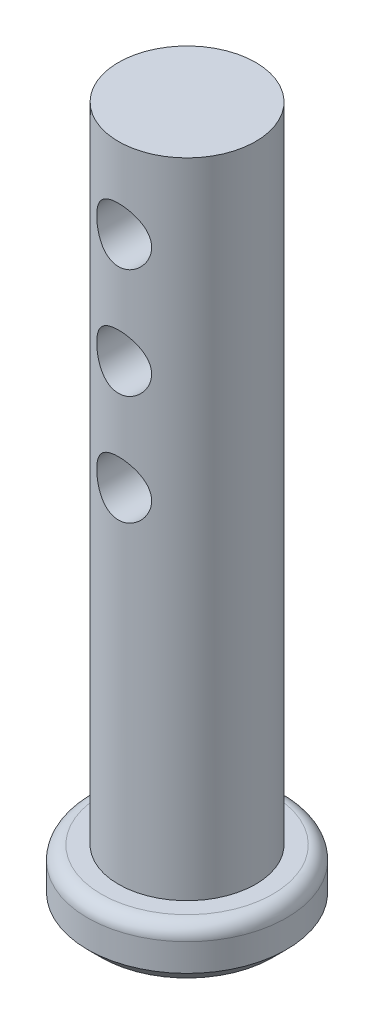
from build123d import *

# Parameters (mm, degrees)
SKETCH1_R               = 4.60375
BOSS_EXTRUDE1_DEPTH     = 2.54
SKETCH2_R               = 3.175
BOSS_EXTRUDE2_DEPTH     = 45.72
SKETCH3_R               = 1.27
CUT_EXTRUDE1_DEPTH      = 5.60375
CUT_EXTRUDE1_DEPTH_BACK = 5.60375
FILLET1_R               = 0.635
CHAMFER1_SIZE           = 0.635
SKETCH4_W               = 16.845680721
SKETCH4_H               = 19.604839444
CUT_EXTRUDE2_DEPTH      = 5.60375
CUT_EXTRUDE2_DEPTH_BACK = 5.6037501


with BuildPart() as part:
    # Sketch1 → Boss-Extrude1 (new body)
    with BuildSketch(Plane(origin=(0, 0, 0), x_dir=(1, 0, 0), z_dir=(0, 1, 0))):
        Circle(SKETCH1_R)
    extrude(amount=BOSS_EXTRUDE1_DEPTH)

    # Sketch2 → Boss-Extrude2 (add)
    with BuildSketch(Plane(origin=(0, 2.54, 0), x_dir=(1, 0, 0), z_dir=(0, 1, 0))):
        Circle(SKETCH2_R)
    extrude(amount=BOSS_EXTRUDE2_DEPTH)

    # Sketch3 → Cut-Extrude1 (cut, two sides)
    with BuildSketch(Plane.XY) as cut_extrude1_sk:
        with Locations((0, 18.415)):
            Circle(SKETCH3_R)
        with Locations((0, 23.495)):
            Circle(SKETCH3_R)
        with Locations((0, 28.575)):
            Circle(SKETCH3_R)
        with Locations((0, 33.655)):
            Circle(SKETCH3_R)
        with Locations((0, 38.735)):
            Circle(SKETCH3_R)
        with Locations((0, 43.815)):
            Circle(SKETCH3_R)
    extrude(amount=CUT_EXTRUDE1_DEPTH, mode=Mode.SUBTRACT)
    extrude(cut_extrude1_sk.sketch, amount=-CUT_EXTRUDE1_DEPTH_BACK, mode=Mode.SUBTRACT)

    # Fillet1
    fillet1_edges = [part.edges().sort_by_distance(p)[0] for p in [
        (-4.60375, 2.54, 0),
    ]]
    fillet(fillet1_edges, radius=FILLET1_R)

    # Chamfer1
    chamfer1_edges = [part.edges().sort_by_distance(p)[0] for p in [
        (-4.60375, 0, 0),
    ]]
    chamfer(chamfer1_edges, length=CHAMFER1_SIZE)

    # Sketch4 → Cut-Extrude2 (cut, two sides)
    with BuildSketch(Plane(origin=(0, 0, 0), x_dir=(0, 0, -1), z_dir=(1, 0, 0))) as cut_extrude2_sk:
        with Locations((1.010740844, 42.122953468)):
            Rectangle(SKETCH4_W, SKETCH4_H)
    extrude(amount=CUT_EXTRUDE2_DEPTH, mode=Mode.SUBTRACT)
    extrude(cut_extrude2_sk.sketch, amount=-CUT_EXTRUDE2_DEPTH_BACK, mode=Mode.SUBTRACT)


solid = part.part
